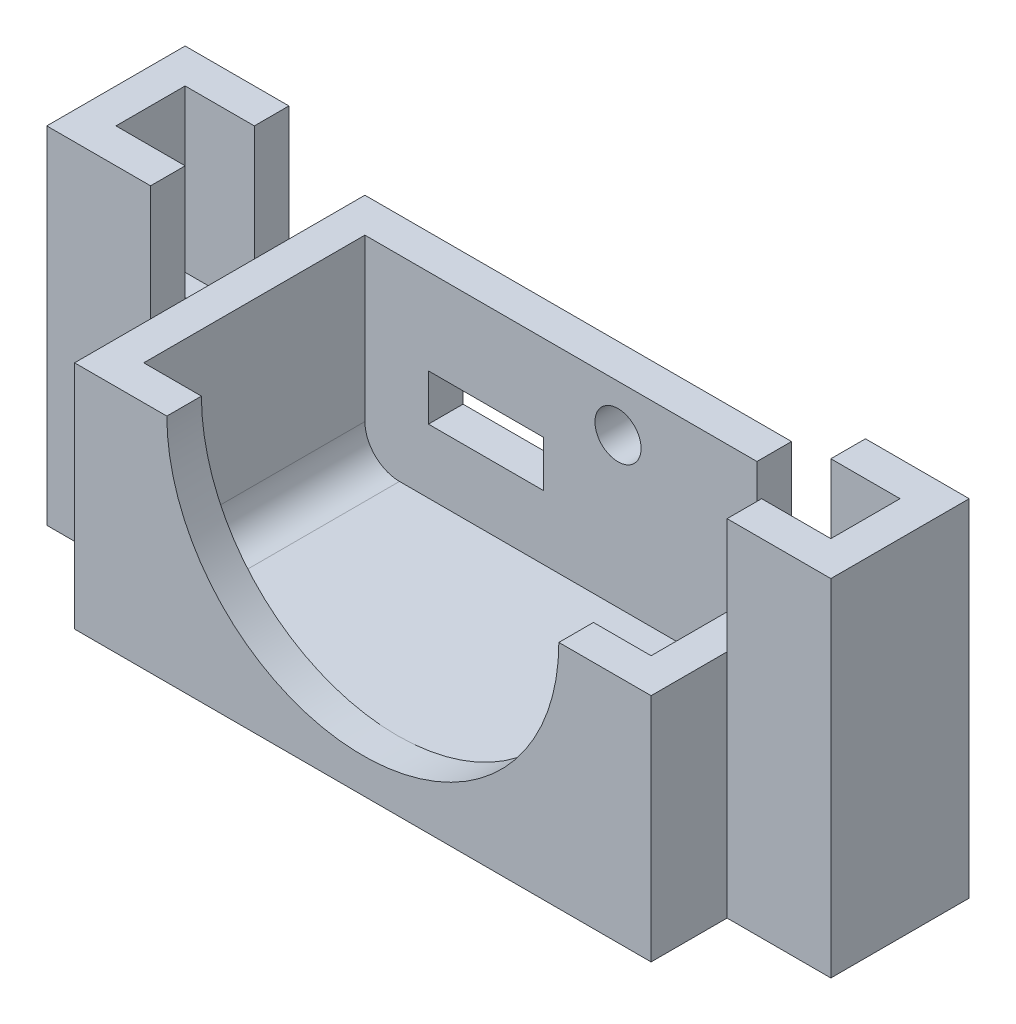
from build123d import *

# Parameters (mm, degrees)
SKETCH1_W           = 50
SKETCH1_H           = 25.18
BOSS_EXTRUDE1_DEPTH = 20
SKETCH2_W           = 44
SKETCH2_H           = 19.18
CUT_EXTRUDE1_DEPTH  = 17
CUT_EXTRUDE2_DEPTH  = 3
SKETCH5_R           = 2
SKETCH5_W           = 0.418499832
SKETCH5_H           = 1.291345909
SKETCH5_W_2         = 10
SKETCH5_H_2         = 6
SKETCH5_H_3         = 4
CUT_EXTRUDE3_DEPTH  = 3
FILLET1_R           = 3
SKETCH7_W           = 6
SKETCH7_H           = 6
SKETCH7_R           = 1.5
BOSS_EXTRUDE2_DEPTH = 16
BOSS_EXTRUDE3_DEPTH = 30


with BuildPart() as part:
    # Sketch1 → Boss-Extrude1 (new body)
    with BuildSketch(Plane(origin=(0, 0, 0), x_dir=(1, 0, 0), z_dir=(0, 1, 0))):
        Rectangle(SKETCH1_W, SKETCH1_H)
    extrude(amount=BOSS_EXTRUDE1_DEPTH)

    # Sketch2 → Cut-Extrude1 (cut)
    with BuildSketch(Plane(origin=(0, 20, 0), x_dir=(1, 0, 0), z_dir=(0, 1, 0))):
        Rectangle(SKETCH2_W, SKETCH2_H)
    extrude(amount=-CUT_EXTRUDE1_DEPTH, mode=Mode.SUBTRACT)

    # Sketch4 → Cut-Extrude2 (cut)
    with BuildSketch(Plane.XY.offset(12.59)):
        with BuildLine():
            Line((-17, 20), (17, 20))
            ThreePointArc((17, 20), (0, 3), (-17, 20))
        make_face()
    extrude(amount=-CUT_EXTRUDE2_DEPTH, mode=Mode.SUBTRACT)

    # Sketch5 → Cut-Extrude3 (cut)
    with BuildSketch(Plane(origin=(0, 0, -12.59), x_dir=(-1, 0, 0), z_dir=(0, 0, -1))):
        with Locations((0.05, 15.95)):
            Circle(SKETCH5_R)
        with Locations((-49.48479677, 33.064984315)):
            Rectangle(SKETCH5_W, SKETCH5_H)
        with Locations((-17, 17)):
            Rectangle(SKETCH5_W_2, SKETCH5_H_2)
        with Locations((11.49, 10.56)):
            Rectangle(SKETCH5_W_2, SKETCH5_H_3)
    extrude(amount=-CUT_EXTRUDE3_DEPTH, mode=Mode.SUBTRACT)

    # Fillet1
    fillet1_edges = [part.edges().sort_by_distance(p)[0] for p in [
        (22, 3, 0),
        (-22, 3, 0),
    ]]
    fillet(fillet1_edges, radius=FILLET1_R)

    # Sketch7 → Boss-Extrude2 (add)
    with BuildSketch(Plane.XZ):
        with Locations((-28, 0)):
            Rectangle(SKETCH7_W, SKETCH7_H)
        with Locations((-28, 0)):
            Circle(SKETCH7_R, mode=Mode.SUBTRACT)
        with Locations((28, 0)):
            Rectangle(SKETCH7_W, SKETCH7_H)
        with Locations((28, 0)):
            Circle(SKETCH7_R, mode=Mode.SUBTRACT)
    extrude(amount=-BOSS_EXTRUDE2_DEPTH)

    # Sketch8 → Boss-Extrude3 (add)
    with BuildSketch(Plane.XZ):
        Polygon((-25, -6), (-34, -6), (-34, 6), (-25, 6), (-25, 3), (-31, 3), (-31, -3), (-25, -3), align=None)
        Polygon((25, 3), (25, 6), (34, 6), (34, -6), (25, -6), (25, -3), (31, -3), (31, 3), align=None)
    extrude(amount=-BOSS_EXTRUDE3_DEPTH)


solid = part.part
